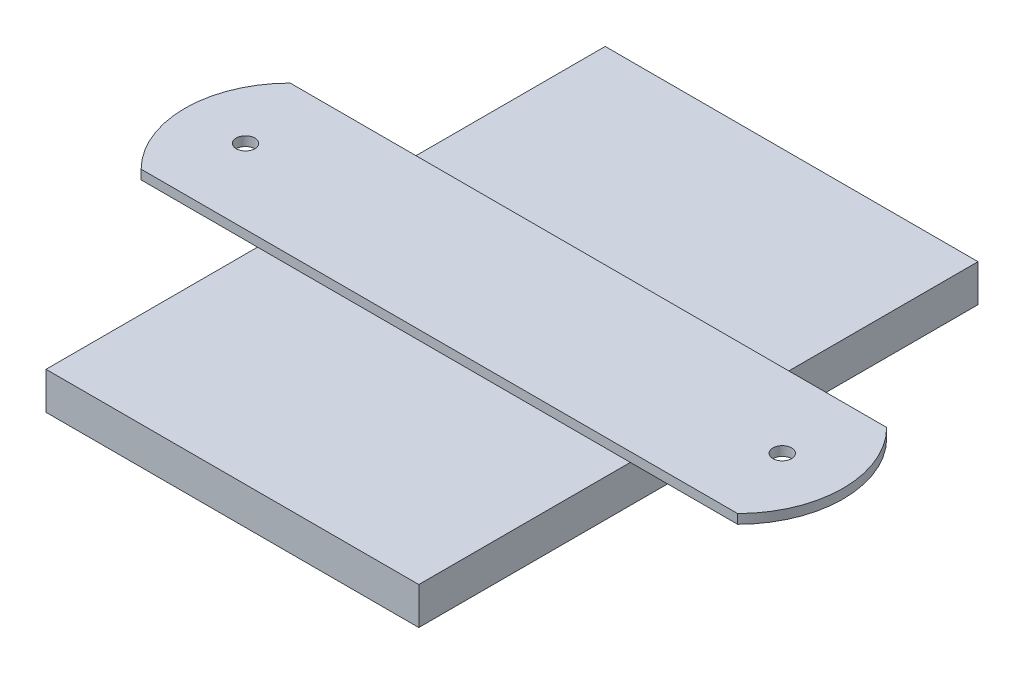
from build123d import *

# Parameters (mm, degrees)
SKETCH1_W           = 63.5
SKETCH1_H           = 95.25
BOSS_EXTRUDE1_DEPTH = 3.175
SKETCH2_R           = 1.5875
BOSS_EXTRUDE2_DEPTH = 1.5875


with BuildPart() as part:
    # Sketch1 → Boss-Extrude1 (new body, symmetric)
    with BuildSketch(Plane(origin=(0, 0, 0), x_dir=(1, 0, 0), z_dir=(0, 1, 0))):
        with Locations((31.75, 47.625)):
            Rectangle(SKETCH1_W, SKETCH1_H)
    extrude(amount=BOSS_EXTRUDE1_DEPTH, both=True)

    # Sketch2 → Boss-Extrude2 (add)
    with BuildSketch(Plane(origin=(0, 3.175, 0), x_dir=(1, 0, 0), z_dir=(0, 1, 0))):
        with BuildLine():
            Line((-19.831384914, 36.032499706), (81.768615086, 36.032499706))
            ThreePointArc((81.768615086, 36.032499706), (87.029127328, 48.732499706), (81.768615086, 61.432499706))
            Line((81.768615086, 61.432499706), (-19.831384914, 61.432499706))
            ThreePointArc((-19.831384914, 61.432499706), (-25.091897156, 48.732499706), (-19.831384914, 36.032499706))
        make_face()
        with Locations((-14.743661756, 48.732499706)):
            Circle(SKETCH2_R, mode=Mode.SUBTRACT)
        with Locations((76.680891929, 48.732499706)):
            Circle(SKETCH2_R, mode=Mode.SUBTRACT)
    extrude(amount=BOSS_EXTRUDE2_DEPTH)


solid = part.part
